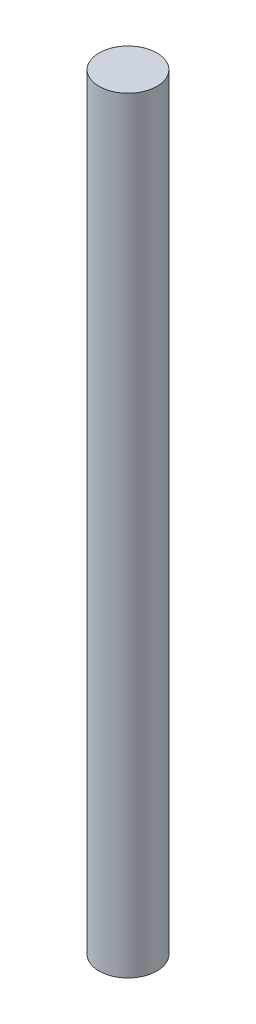
from build123d import *

# Parameters (mm, degrees)
SKETCH1_R           = 3.175
BOSS_EXTRUDE1_DEPTH = 84.074


with BuildPart() as part:
    # Sketch1 → Boss-Extrude1 (new body)
    with BuildSketch(Plane(origin=(0, 0, 0), x_dir=(1, 0, 0), z_dir=(0, 1, 0))):
        Circle(SKETCH1_R)
    extrude(amount=BOSS_EXTRUDE1_DEPTH)


solid = part.part
